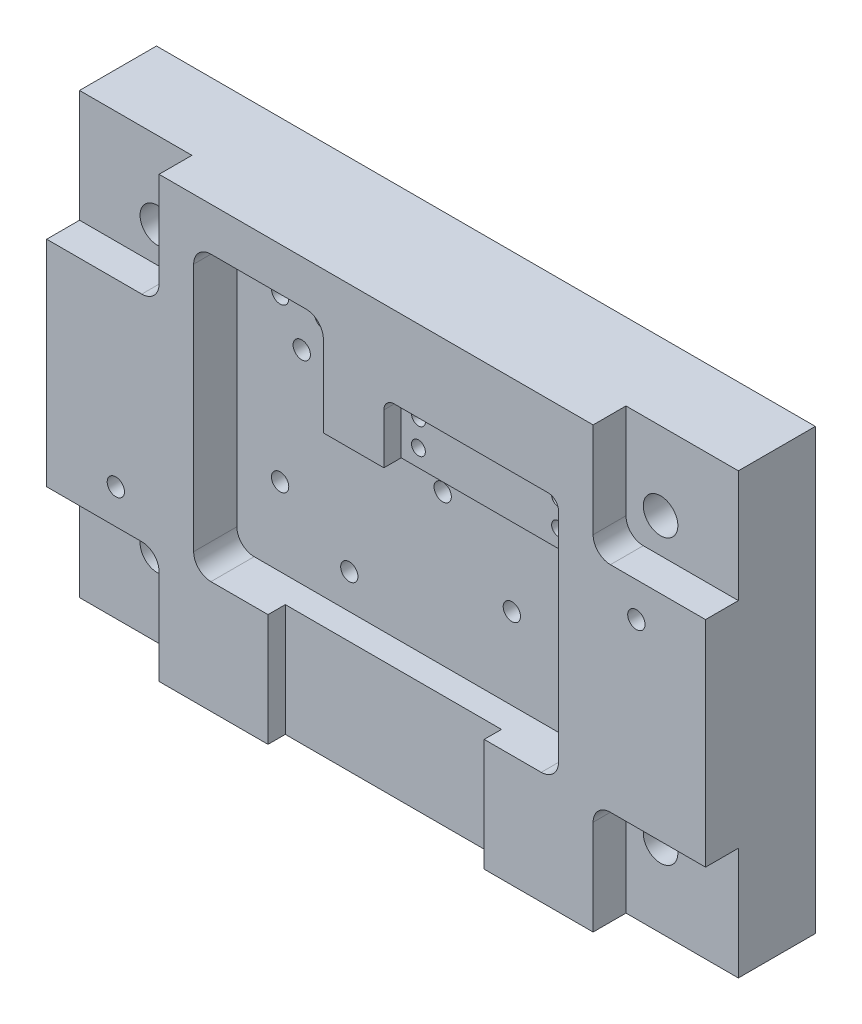
from build123d import *

# Parameters (mm, degrees)
CROQUIS1_W                      = 381
CROQUIS1_H                      = 254
SALIENTE_EXTRUIR1_DEPTH         = 63.5
CROQUIS2_W                      = 65
CROQUIS2_H                      = 65
CORTAR_EXTRUIR1_DEPTH           = 19
CORTAR_EXTRUIR2_DEPTH           = 10
CORTAR_EXTRUIR3_DEPTH           = 15
DI_METRO_DE_TALADRO_20_0_20_1_D = 20
DI_METRO_DE_TALADRO_10_0_10_1_D = 10
DI_METRO_DE_TALADRO_10_0_10_2_D = 10
DI_METRO_DE_TALADRO_8_0_8_1_D   = 8
REDONDEO1_R                     = 10
REDONDEO2_R                     = 6


with BuildPart() as part:
    # Croquis1 → Saliente-Extruir1 (new body)
    with BuildSketch(Plane.XY):
        Rectangle(CROQUIS1_W, CROQUIS1_H)
    extrude(amount=SALIENTE_EXTRUIR1_DEPTH)

    # Croquis2 → Cortar-Extruir1 (cut)
    with BuildSketch(Plane.XY.offset(63.5)):
        with Locations((-158, 94.5)):
            Rectangle(CROQUIS2_W, CROQUIS2_H)
        with Locations((-158, -94.5)):
            Rectangle(CROQUIS2_W, CROQUIS2_H)
        with Locations((158, -94.5)):
            Rectangle(CROQUIS2_W, CROQUIS2_H)
        with Locations((158, 94.5)):
            Rectangle(CROQUIS2_W, CROQUIS2_H)
    extrude(amount=-CORTAR_EXTRUIR1_DEPTH, mode=Mode.SUBTRACT)

    # Croquis3 → Cortar-Extruir2 (cut)
    with BuildSketch(Plane.XY.offset(63.5)):
        Polygon((62.5, -127), (62.5, -62), (105.5, -62), (105.5, 80), (4.5, 80), (4.5, 45), (-30.5, 45), (-30.5, 102), (-105.5, 102), (-105.5, -62), (-62.5, -62), (-62.5, -127), align=None)
    extrude(amount=-CORTAR_EXTRUIR2_DEPTH, mode=Mode.SUBTRACT)

    # Croquis4 → Cortar-Extruir3 (cut)
    with BuildSketch(Plane.XY.offset(53.5)):
        Polygon((105.5, -62), (105.5, 45), (-30.5, 45), (-30.5, 102), (-105.5, 102), (-105.5, -62), align=None)
    extrude(amount=-CORTAR_EXTRUIR3_DEPTH, mode=Mode.SUBTRACT)

    # Diámetro de taladro Ø20.0 (20)1 (through all)
    with Locations(Plane.XY.offset(44.5)):
        with Locations((-145.5, 82), (-145.5, -82), (145.5, -82), (145.5, 82)):
            Hole(DI_METRO_DE_TALADRO_20_0_20_1_D / 2)

    # Diámetro de taladro Ø10.0 (10)1 (through all)
    with Locations(Plane.XY.offset(38.5)):
        with Locations((-80.5, 77), (-55.5, 77), (-68, 55.349364905), (-80.5, -17), (-40.5, -42), (13.5, 25), (53.5, -15), (93.5, 25), (93.5, -42)):
            Hole(DI_METRO_DE_TALADRO_10_0_10_1_D / 2)

    # Diámetro de taladro Ø10.0 (10)2 (through all)
    with Locations(Plane.XY.offset(63.5)):
        with Locations((-150.5, -42), (150.5, 42)):
            Hole(DI_METRO_DE_TALADRO_10_0_10_2_D / 2)

    # Diámetro de taladro Ø8.0 (8)1 (through all)
    with Locations(Plane.XY.offset(53.5)):
        with Locations((14.5, 70), (95.5, 70), (95.5, 55), (14.5, 55)):
            Hole(DI_METRO_DE_TALADRO_8_0_8_1_D / 2)

    # Redondeo1
    redondeo1_edges = [part.edges().sort_by_distance(p)[0] for p in [
        (105.5, 45, 46),
        (125.5, 62, 54),
        (125.5, -62, 54),
        (-125.5, -62, 54),
        (-125.5, 62, 54),
        (-105.5, -62, 51),
        (-105.5, 102, 51),
        (-30.5, 102, 51),
        (105.5, -62, 51),
    ]]
    fillet(redondeo1_edges, radius=REDONDEO1_R)

    # Redondeo2
    redondeo2_edges = [part.edges().sort_by_distance(p)[0] for p in [
        (4.5, 80, 58.5),
        (105.5, 80, 58.5),
    ]]
    fillet(redondeo2_edges, radius=REDONDEO2_R)


solid = part.part
